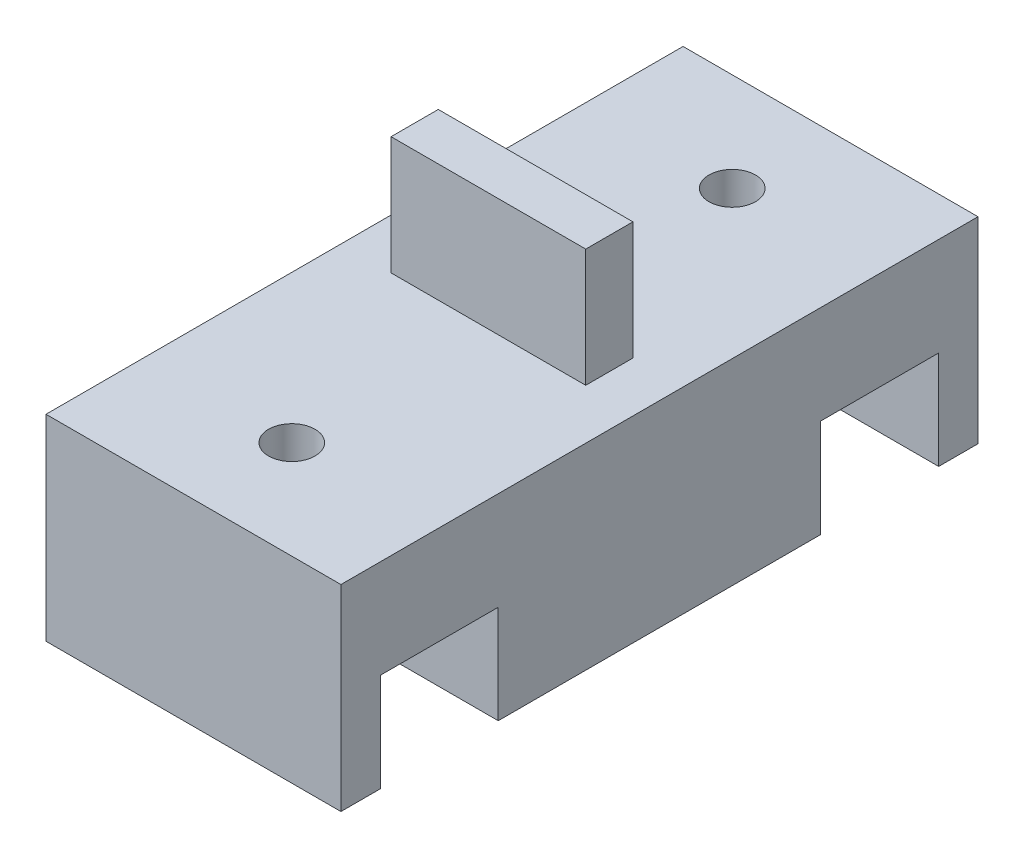
from build123d import *

# Parameters (mm, degrees)
BOSS_EXTRUDE1_DEPTH = 9.525
SKETCH1_3_W         = 3.048
SKETCH1_3_H         = 7.62
BOSS_EXTRUDE2_DEPTH = 6.2865
SKETCH4_R           = 1.5
CUT_EXTRUDE3_DEPTH  = 26.986633122
CUT_EXTRUDE4_START  = -6.35
SKETCH5_W           = 19.05
SKETCH5_H           = 7.62
SKETCH5_R           = 1.5
CUT_EXTRUDE4_DEPTH  = 6.35


with BuildPart() as part:
    # Sketch1 → Boss-Extrude1 (new, symmetric)
    with BuildSketch(Plane(origin=(0, 0, 0), x_dir=(0, 0, -1), z_dir=(1, 0, 0))):
        Polygon((-1.524, 12.7), (-20.574, 12.7), (-20.574, 0), (20.574, 0), (20.574, 12.7), (1.524, 12.7), align=None)
    extrude(amount=BOSS_EXTRUDE1_DEPTH, both=True)

    # Sketch1_3 → Boss-Extrude2 (add, symmetric)
    with BuildSketch(Plane(origin=(0, 0, 0), x_dir=(0, 0, -1), z_dir=(1, 0, 0))):
        with Locations((0, 16.51)):
            Rectangle(SKETCH1_3_W, SKETCH1_3_H)
    extrude(amount=BOSS_EXTRUDE2_DEPTH, both=True)

    # Sketch4 → Cut-Extrude3 (cut, through all)
    with BuildSketch(Plane(origin=(0, 12.7, 0), x_dir=(1, 0, 0), z_dir=(0, 1, 0))):
        with Locations((0, -14.224)):
            Circle(SKETCH4_R)
        with Locations((0, 14.224)):
            Circle(SKETCH4_R)
    extrude(amount=-CUT_EXTRUDE3_DEPTH, mode=Mode.SUBTRACT)

    # Sketch5 → Cut-Extrude4 (cut)
    # profile 1 of 2: a face of its own
    with BuildSketch(Plane.XZ.offset(CUT_EXTRUDE4_START)):
        with Locations((0, -14.224)):
            Rectangle(SKETCH5_W, SKETCH5_H)
        with Locations((0, -14.224)):
            Circle(SKETCH5_R, mode=Mode.SUBTRACT)
    # profile 2 of 2: a face of its own
    with BuildSketch(Plane.XZ.offset(CUT_EXTRUDE4_START)):
        with Locations((0, 14.224)):
            Rectangle(SKETCH5_W, SKETCH5_H)
        with Locations((0, 14.224)):
            Circle(SKETCH5_R, mode=Mode.SUBTRACT)
    extrude(amount=CUT_EXTRUDE4_DEPTH, mode=Mode.SUBTRACT)


solid = part.part
